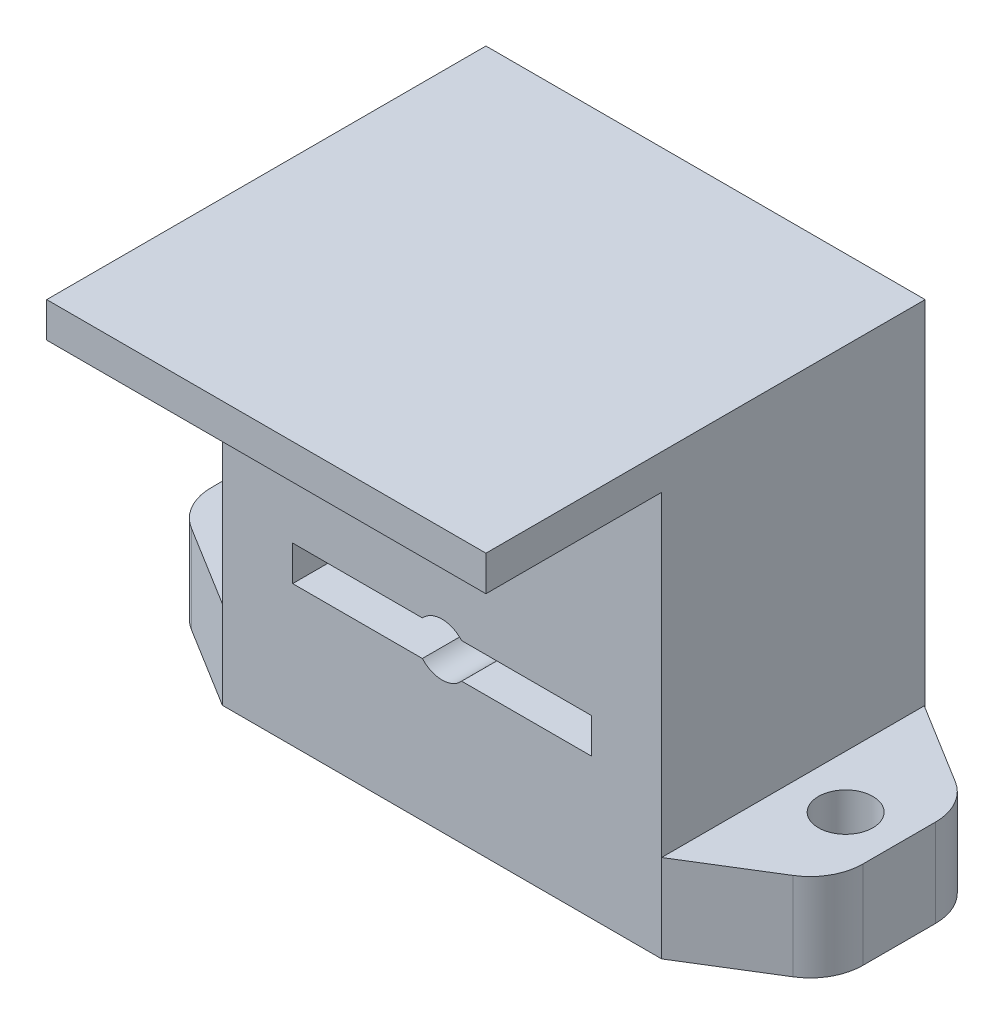
from build123d import *

# Parameters (mm, degrees)
SKETCH1_W           = 25
SKETCH1_H           = 23
BOSS_EXTRUDE1_DEPTH = 15
BOSS_EXTRUDE4_DEPTH = 5
SKETCH3_R           = 1.55
BOSS_EXTRUDE5_DEPTH = 5
SKETCH1_6_W         = 25
SKETCH1_6_H         = 2
BOSS_EXTRUDE6_DEPTH = 25


with BuildPart() as part:
    # Sketch1 → Boss-Extrude1 (new body)
    with BuildSketch(Plane.XY):
        with Locations((0, -1)):
            Rectangle(SKETCH1_W, SKETCH1_H)
        with BuildLine():
            Line((8.5, -2.5), (8.5, -4.5))
            Line((8.5, -4.5), (1.118033989, -4.5))
            ThreePointArc((1.118033989, -4.5), (0, -5), (-1.118033989, -4.5))
            Line((-1.118033989, -4.5), (-8.5, -4.5))
            Line((-8.5, -4.5), (-8.5, -2.5))
            Line((-8.5, -2.5), (-1.118033989, -2.5))
            ThreePointArc((-1.118033989, -2.5), (0, -2), (1.118033989, -2.5))
            Line((1.118033989, -2.5), (8.5, -2.5))
        make_face(mode=Mode.SUBTRACT)
        with BuildLine():
            Line((8.5, 9.5), (8.5, 7.5))
            Line((8.5, 7.5), (1.118033989, 7.5))
            ThreePointArc((1.118033989, 7.5), (0, 7), (-1.118033989, 7.5))
            Line((-1.118033989, 7.5), (-8.5, 7.5))
            Line((-8.5, 7.5), (-8.5, 9.5))
            Line((-8.5, 9.5), (-1.118033989, 9.5))
            ThreePointArc((-1.118033989, 9.5), (0, 10), (1.118033989, 9.5))
            Line((1.118033989, 9.5), (8.5, 9.5))
        make_face(mode=Mode.SUBTRACT)
    extrude(amount=BOSS_EXTRUDE1_DEPTH)

    # Sketch1_5 → Boss-Extrude4 (add)
    with BuildSketch(Plane.XY):
        with BuildLine():
            Line((1.118033989, -4.5), (8.5, -4.5))
            Line((8.5, -4.5), (8.5, -2.5))
            Line((8.5, -2.5), (1.118033989, -2.5))
            ThreePointArc((1.118033989, -2.5), (1.5, -3.5), (1.118033989, -4.5))
        make_face()
        with BuildLine():
            Line((-8.5, -4.5), (-1.118033989, -4.5))
            ThreePointArc((-1.118033989, -4.5), (-1.5, -3.5), (-1.118033989, -2.5))
            Line((-1.118033989, -2.5), (-8.5, -2.5))
            Line((-8.5, -2.5), (-8.5, -4.5))
        make_face()
        with BuildLine():
            Line((1.118033989, 7.5), (8.5, 7.5))
            Line((8.5, 7.5), (8.5, 9.5))
            Line((8.5, 9.5), (1.118033989, 9.5))
            ThreePointArc((1.118033989, 9.5), (1.5, 8.5), (1.118033989, 7.5))
        make_face()
        with BuildLine():
            Line((-8.5, 7.5), (-1.118033989, 7.5))
            ThreePointArc((-1.118033989, 7.5), (-1.5, 8.5), (-1.118033989, 9.5))
            Line((-1.118033989, 9.5), (-8.5, 9.5))
            Line((-8.5, 9.5), (-8.5, 7.5))
        make_face()
    extrude(amount=BOSS_EXTRUDE4_DEPTH)

    # Sketch3 → Boss-Extrude5 (add)
    # profile 1 of 2: a face of its own
    with BuildSketch(Plane.XZ.offset(12.5)):
        with BuildLine():
            ThreePointArc((17.125197634, 2.909179163), (18.168457468, 4.000265566), (18.548267571, 5.461294281))
            Line((18.548267571, 5.461294281), (18.548267571, 9.590014896))
            ThreePointArc((18.548267571, 9.590014896), (18.168457468, 11.051043611), (17.125197634, 12.142130014))
            Line((17.125197634, 12.142130014), (12.5, 15))
            Line((12.5, 15), (12.5, 0.051309177))
            Line((12.5, 0.051309177), (17.125197634, 2.909179163))
        make_face()
        with Locations((15.5, 7.525654589)):
            Circle(SKETCH3_R, mode=Mode.SUBTRACT)
    # profile 2 of 2: a face of its own
    with BuildSketch(Plane.XZ.offset(12.5)):
        with BuildLine():
            Line((-12.5, 15), (-17.125197634, 12.142130014))
            ThreePointArc((-17.125197634, 12.142130014), (-18.168457468, 11.051043611), (-18.548267571, 9.590014896))
            Line((-18.548267571, 9.590014896), (-18.548267571, 5.461294281))
            ThreePointArc((-18.548267571, 5.461294281), (-18.168457468, 4.000265566), (-17.125197634, 2.909179163))
            Line((-17.125197634, 2.909179163), (-12.5, 0.051309177))
            Line((-12.5, 0.051309177), (-12.5, 15))
        make_face()
        with Locations((-15.5, 7.525654589)):
            Circle(SKETCH3_R, mode=Mode.SUBTRACT)
    extrude(amount=-BOSS_EXTRUDE5_DEPTH)

    # Sketch1_6 → Boss-Extrude6 (add)
    with BuildSketch(Plane.XY):
        with Locations((0, 11.5)):
            Rectangle(SKETCH1_6_W, SKETCH1_6_H)
    extrude(amount=BOSS_EXTRUDE6_DEPTH)


solid = part.part
